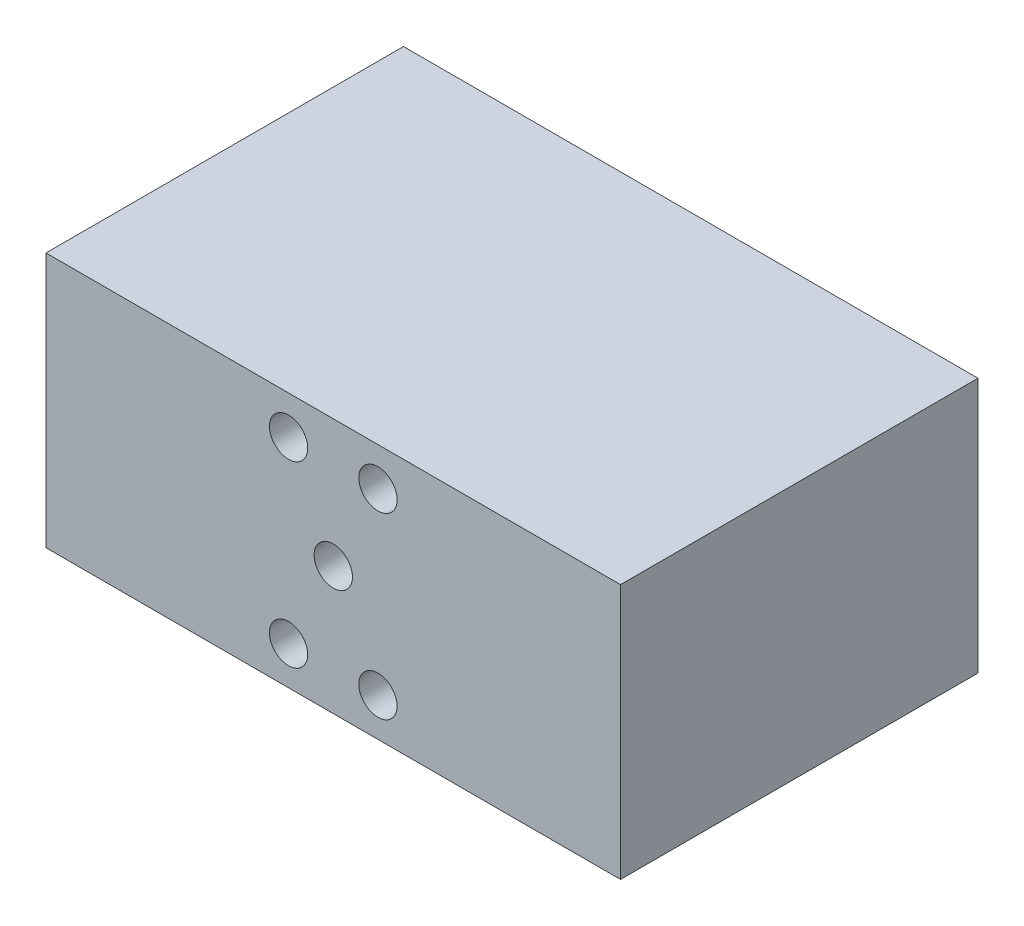
from build123d import *

# Parameters (mm, degrees)
SKETCH2_W           = 45
SKETCH2_H           = 20
BOSS_EXTRUDE1_DEPTH = 28
SKETCH3_R           = 1.5
CUT_EXTRUDE1_DEPTH  = 28


with BuildPart() as part:
    # Sketch2 → Boss-Extrude1 (new body)
    with BuildSketch(Plane.XY):
        with Locations((22.5, 10)):
            Rectangle(SKETCH2_W, SKETCH2_H)
    extrude(amount=-BOSS_EXTRUDE1_DEPTH)

    # Sketch3 → Cut-Extrude1 (cut)
    with BuildSketch(Plane.XY):
        with Locations((22.5, 10.010662988)):
            Circle(SKETCH3_R)
        with Locations((19, 17.000059599)):
            Circle(SKETCH3_R)
        with Locations((19, 2.999940401)):
            Circle(SKETCH3_R)
        with Locations((26, 2.999940401)):
            Circle(SKETCH3_R)
        with Locations((26, 17.000059599)):
            Circle(SKETCH3_R)
    extrude(amount=-CUT_EXTRUDE1_DEPTH, mode=Mode.SUBTRACT)


solid = part.part
